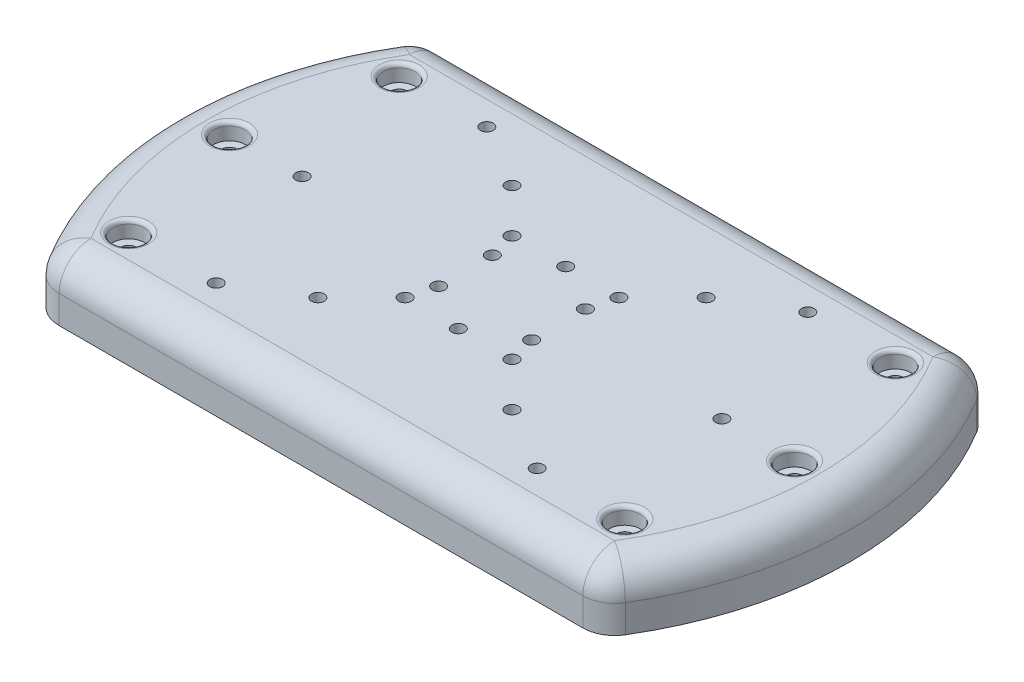
from build123d import *

# Parameters (mm, degrees)
SKETCH_1_R          = 1.6
SKETCH_1_R_2        = 2
EXTRUDE_1_DEPTH     = 15
FILLET_1_R          = 8
SKETCH_2_R          = 4
CUT_EXTRUDE_1_DEPTH = 4.2
SKETCH_3_R          = 3.3
CUT_EXTRUDE_2_DEPTH = 3.2
FILLET_2_R          = 1


with BuildPart() as part:
    # 草图1 → 凸台-拉伸1 (new body)
    with BuildSketch(Plane(origin=(0, 0, 0), x_dir=(1, 0, 0), z_dir=(0, 1, 0))):
        with BuildLine():
            Line((-70.149839629, 48), (70.149839629, 48))
            ThreePointArc((70.149839629, 48), (85, 0), (70.149839629, -48))
            Line((70.149839629, -48), (-70.149839629, -48))
            ThreePointArc((-70.149839629, -48), (-85, 0), (-70.149839629, 48))
        make_face()
        with Locations((0, 13.5)):
            Circle(SKETCH_1_R, mode=Mode.SUBTRACT)
        with Locations((-11.691342951, 6.75)):
            Circle(SKETCH_1_R, mode=Mode.SUBTRACT)
        with Locations((11.691342951, 6.75)):
            Circle(SKETCH_1_R, mode=Mode.SUBTRACT)
        with Locations((11.691342951, -6.75)):
            Circle(SKETCH_1_R, mode=Mode.SUBTRACT)
        with Locations((-11.691342951, -6.75)):
            Circle(SKETCH_1_R, mode=Mode.SUBTRACT)
        with Locations((0, -13.5)):
            Circle(SKETCH_1_R, mode=Mode.SUBTRACT)
        with Locations((-62.342360606, 34)):
            Circle(SKETCH_1_R_2, mode=Mode.SUBTRACT)
        with Locations((-71, 0)):
            Circle(SKETCH_1_R_2, mode=Mode.SUBTRACT)
        with Locations((-62.329768169, -34)):
            Circle(SKETCH_1_R_2, mode=Mode.SUBTRACT)
        with Locations((71, 0)):
            Circle(SKETCH_1_R_2, mode=Mode.SUBTRACT)
        with Locations((62.329768169, -34)):
            Circle(SKETCH_1_R_2, mode=Mode.SUBTRACT)
        with Locations((62.329768169, 34)):
            Circle(SKETCH_1_R_2, mode=Mode.SUBTRACT)
        with Locations((-24.395183951, 24.395183951)):
            Circle(SKETCH_1_R, mode=Mode.SUBTRACT)
        with Locations((24.395183951, 24.395183951)):
            Circle(SKETCH_1_R, mode=Mode.SUBTRACT)
        with Locations((24.395183951, -24.395183951)):
            Circle(SKETCH_1_R, mode=Mode.SUBTRACT)
        with Locations((-24.395183951, -24.395183951)):
            Circle(SKETCH_1_R, mode=Mode.SUBTRACT)
        with Locations((13.435028843, 13.435028843)):
            Circle(SKETCH_1_R, mode=Mode.SUBTRACT)
        with Locations((-13.435028843, 13.435028843)):
            Circle(SKETCH_1_R, mode=Mode.SUBTRACT)
        with Locations((-13.435028843, -13.435028843)):
            Circle(SKETCH_1_R, mode=Mode.SUBTRACT)
        with Locations((13.435028843, -13.435028843)):
            Circle(SKETCH_1_R, mode=Mode.SUBTRACT)
        with Locations((-40.330664512, 34)):
            Circle(SKETCH_1_R, mode=Mode.SUBTRACT)
        with Locations((-52.75, 0)):
            Circle(SKETCH_1_R, mode=Mode.SUBTRACT)
        with Locations((-40.330664512, -34)):
            Circle(SKETCH_1_R, mode=Mode.SUBTRACT)
        with Locations((40.330664512, 34)):
            Circle(SKETCH_1_R, mode=Mode.SUBTRACT)
        with Locations((52.75, 0)):
            Circle(SKETCH_1_R, mode=Mode.SUBTRACT)
        with Locations((40.330664512, -34)):
            Circle(SKETCH_1_R, mode=Mode.SUBTRACT)
    extrude(amount=EXTRUDE_1_DEPTH)

    # 圆角1
    fillet_1_edges = [part.edges().sort_by_distance(p)[0] for p in [
        (-85, 15, 0),
        (0, 15, 48),
        (85, 15, 0),
        (70.149839629, 7.5, 48),
        (-70.149839629, 7.5, 48),
        (-70.149839629, 7.5, -48),
        (70.149839629, 7.5, -48),
        (0, 15, -48),
    ]]
    fillet(fillet_1_edges, radius=FILLET_1_R)

    # 草图2 → 切除-拉伸1 (cut)
    with BuildSketch(Plane(origin=(0, 15, 0), x_dir=(1, 0, 0), z_dir=(0, 1, 0))):
        with Locations((-62.342360606, 34)):
            Circle(SKETCH_2_R)
        with Locations((-71, 0)):
            Circle(SKETCH_2_R)
        with Locations((-62.329768169, -34)):
            Circle(SKETCH_2_R)
        with Locations((62.329768169, 34)):
            Circle(SKETCH_2_R)
        with Locations((71, 0)):
            Circle(SKETCH_2_R)
        with Locations((62.329768169, -34)):
            Circle(SKETCH_2_R)
    extrude(amount=-CUT_EXTRUDE_1_DEPTH, mode=Mode.SUBTRACT)

    # 草图3 → 切除-拉伸2 (cut)
    with BuildSketch(Plane.XZ):
        with Locations((0, 13.5)):
            Circle(SKETCH_3_R)
        with Locations((-24.395183951, 24.395183951)):
            Circle(SKETCH_3_R)
        with Locations((-24.395183951, -24.395183951)):
            Circle(SKETCH_3_R)
        with Locations((0, -13.5)):
            Circle(SKETCH_3_R)
        with Locations((24.395183951, -24.395183951)):
            Circle(SKETCH_3_R)
        with Locations((24.395183951, 24.395183951)):
            Circle(SKETCH_3_R)
        with Locations((-40.330664512, 34)):
            Circle(SKETCH_3_R)
        with Locations((-52.75, 0)):
            Circle(SKETCH_3_R)
        with Locations((-40.330664512, -34)):
            Circle(SKETCH_3_R)
        with Locations((40.330664512, 34)):
            Circle(SKETCH_3_R)
        with Locations((52.75, 0)):
            Circle(SKETCH_3_R)
        with Locations((40.330664512, -34)):
            Circle(SKETCH_3_R)
        with BuildLine():
            Line((-16.628193219, 12.602141535), (-14.884507327, 5.917112693))
            ThreePointArc((-14.884507327, 5.917112693), (-10.858455644, 3.556835624), (-8.498178575, 7.582887307))
            Line((-8.498178575, 7.582887307), (-10.241864466, 14.26791615))
            ThreePointArc((-10.241864466, 14.26791615), (-14.26791615, 16.628193219), (-16.628193219, 12.602141535))
        make_face()
        with BuildLine():
            Line((10.241864466, 14.26791615), (8.498178575, 7.582887307))
            ThreePointArc((8.498178575, 7.582887307), (10.858455644, 3.556835624), (14.884507327, 5.917112693))
            Line((14.884507327, 5.917112693), (16.628193219, 12.602141535))
            ThreePointArc((16.628193219, 12.602141535), (14.26791615, 16.628193219), (10.241864466, 14.26791615))
        make_face()
        with BuildLine():
            Line((16.628193219, -12.602141535), (14.884507327, -5.917112693))
            ThreePointArc((14.884507327, -5.917112693), (10.858455644, -3.556835624), (8.498178575, -7.582887307))
            Line((8.498178575, -7.582887307), (10.241864466, -14.26791615))
            ThreePointArc((10.241864466, -14.26791615), (14.26791615, -16.628193219), (16.628193219, -12.602141535))
        make_face()
        with BuildLine():
            Line((-10.241864466, -14.26791615), (-8.498178575, -7.582887307))
            ThreePointArc((-8.498178575, -7.582887307), (-10.858455644, -3.556835624), (-14.884507327, -5.917112693))
            Line((-14.884507327, -5.917112693), (-16.628193219, -12.602141535))
            ThreePointArc((-16.628193219, -12.602141535), (-14.26791615, -16.628193219), (-10.241864466, -14.26791615))
        make_face()
    extrude(amount=-CUT_EXTRUDE_2_DEPTH, mode=Mode.SUBTRACT)

    # 圆角2
    fillet_2_edges = [part.edges().sort_by_distance(p)[0] for p in [
        (-75, 15, 0),
        (-66.329768169, 15, 34),
        (58.329768169, 15, -34),
        (67, 15, 0),
        (58.329768169, 15, 34),
        (-66.342360606, 15, -34),
        (-43.630664512, 0, 34),
        (21.095183951, 0, -24.395183951),
        (21.095183951, 0, 24.395183951),
        (10.858455644, 0, 3.556835624),
        (15.756350273, 0, 9.259627114),
        (14.26791615, 0, 16.628193219),
        (9.370021521, 0, 10.925401729),
        (-14.26791615, 0, 16.628193219),
        (-15.756350273, 0, 9.259627114),
        (-10.858455644, 0, 3.556835624),
        (-9.370021521, 0, 10.925401729),
        (-3.3, 0, -13.5),
        (-27.695183951, 0, -24.395183951),
        (-27.695183951, 0, 24.395183951),
        (14.26791615, 0, -16.628193219),
        (15.756350273, 0, -9.259627114),
        (10.858455644, 0, -3.556835624),
        (9.370021521, 0, -10.925401729),
        (-10.858455644, 0, -3.556835624),
        (-15.756350273, 0, -9.259627114),
        (-14.26791615, 0, -16.628193219),
        (-9.370021521, 0, -10.925401729),
        (-56.05, 0, 0),
        (-43.630664512, 0, -34),
        (37.030664512, 0, 34),
        (49.45, 0, 0),
        (37.030664512, 0, -34),
        (-3.3, 0, 13.5),
    ]]
    fillet(fillet_2_edges, radius=FILLET_2_R)


solid = part.part
